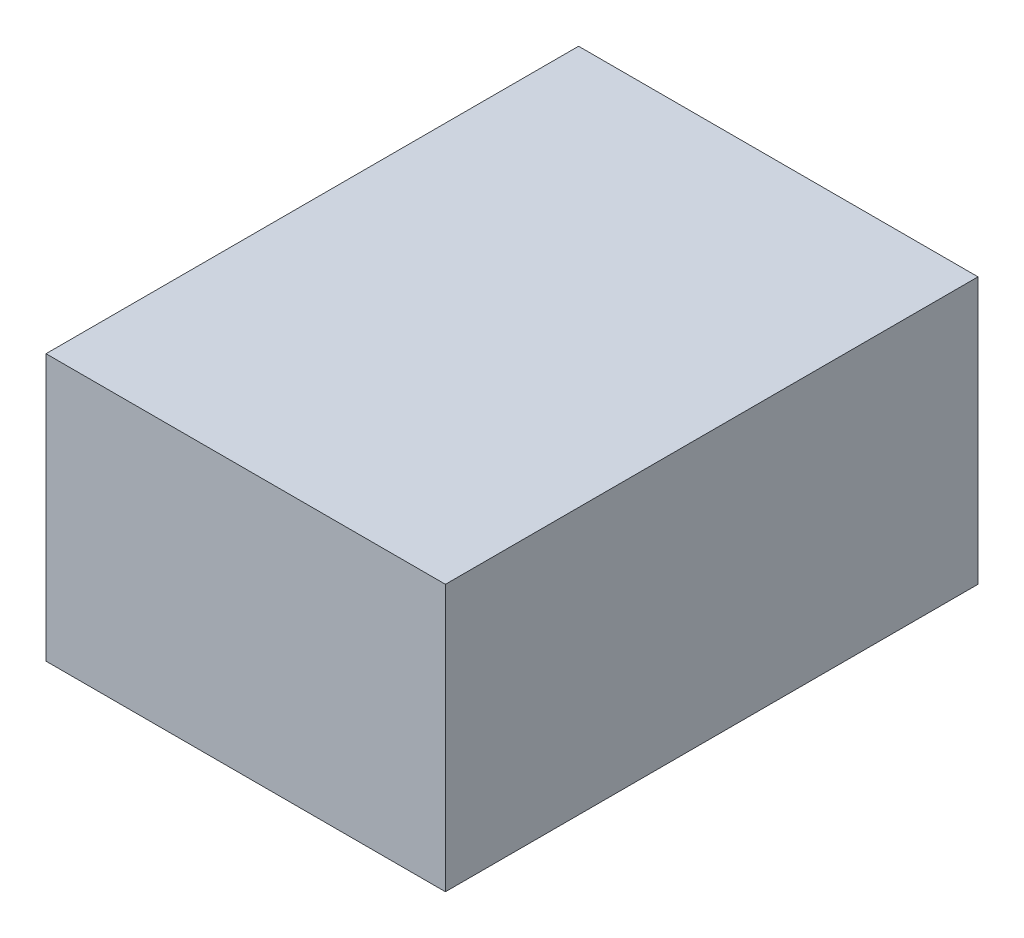
from build123d import *

# Parameters (mm, degrees)
SKETCH1_W           = 6
SKETCH1_H           = 4
BOSS_EXTRUDE1_DEPTH = 8


with BuildPart() as part:
    # Sketch1 → Boss-Extrude1 (new body)
    with BuildSketch(Plane.XY):
        Rectangle(SKETCH1_W, SKETCH1_H)
    extrude(amount=BOSS_EXTRUDE1_DEPTH)


solid = part.part
